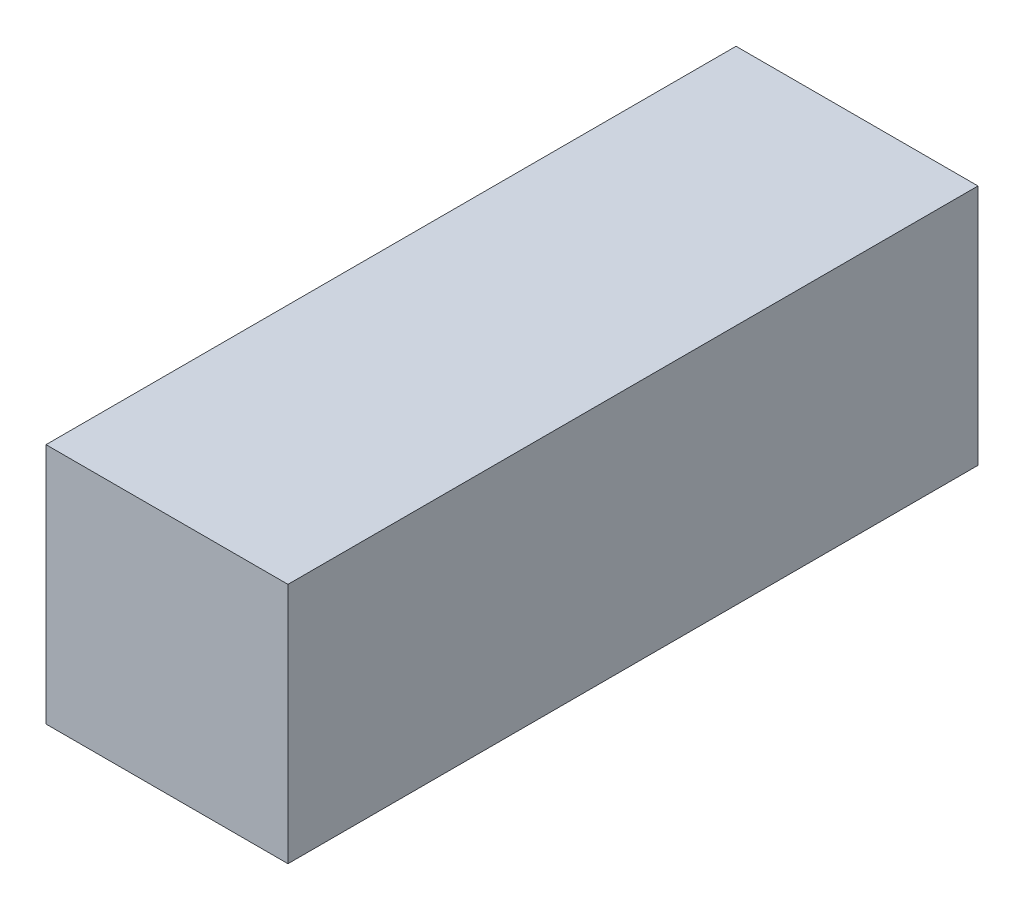
from build123d import *

# Parameters (mm, degrees)
SKETCH2_W           = 7.7
SKETCH2_H           = 2.7
BOSS_EXTRUDE3_DEPTH = 2.7


with BuildPart() as part:
    # Sketch2 → Boss-Extrude3 (new body)
    with BuildSketch(Plane(origin=(0, 0, 0), x_dir=(0, 0, -1), z_dir=(1, 0, 0))):
        Rectangle(SKETCH2_W, SKETCH2_H)
    extrude(amount=BOSS_EXTRUDE3_DEPTH)


solid = part.part
